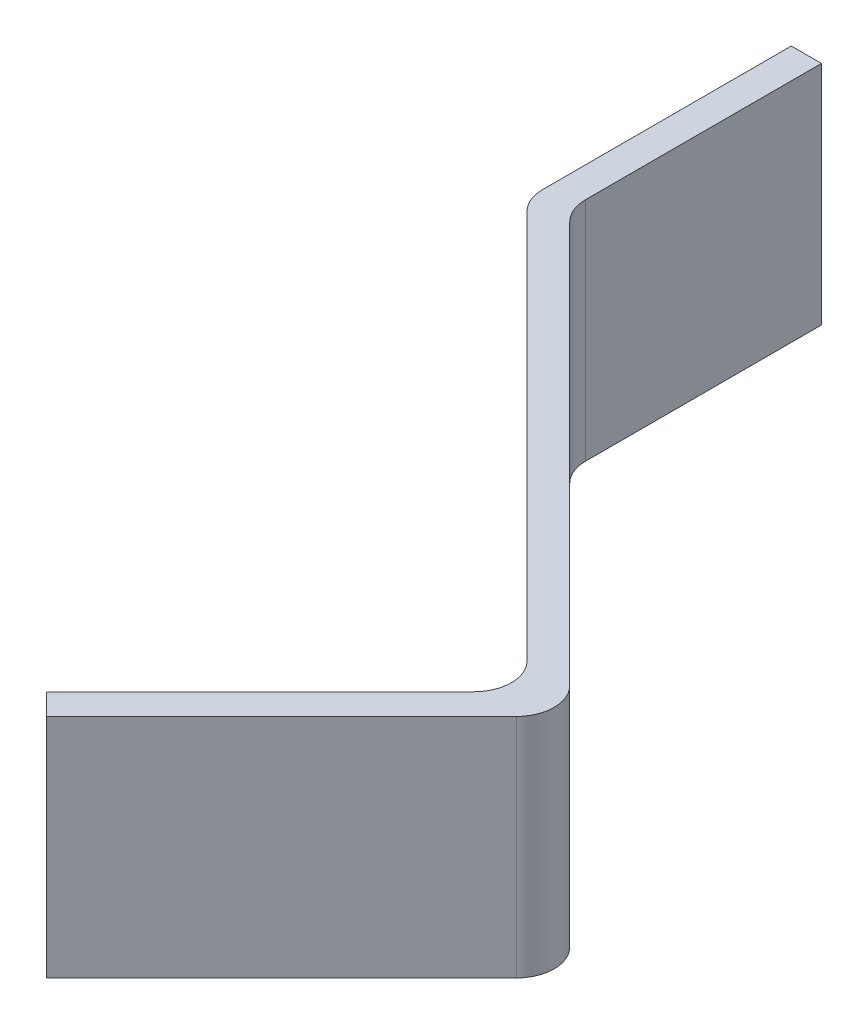
from build123d import *

# Parameters (mm, degrees)
BOSS_EXTRUDE1_DEPTH = 30


with BuildPart() as part:
    # Sketch1 → Boss-Extrude1 (new body)
    with BuildSketch(Plane(origin=(0, 7.5, 0), x_dir=(1, 0, 0), z_dir=(0, 1, 0))):
        with BuildLine():
            Line((248.792121733, 5.17665535), (195.566724989, 58.402052094))
            ThreePointArc((195.566724989, 58.402052094), (194.482861232, 60.024168838), (194.102258895, 61.937586))
            Line((194.102258895, 61.937586), (194.102258895, 93.209663939))
            Line((194.102258895, 93.209663939), (190.102258895, 93.209663939))
            Line((190.102258895, 93.209663939), (190.102258895, 60.280731751))
            ThreePointArc((190.102258895, 60.280731751), (190.482861232, 58.367314589), (191.566724989, 56.745197845))
            Line((191.566724989, 56.745197845), (243.135267484, 5.17665535))
            ThreePointArc((243.135267484, 5.17665535), (244.599733578, 1.641121444), (243.135267484, -1.894412462))
            Line((243.135267484, -1.894412462), (214.850996236, -30.178683709))
            Line((214.850996236, -30.178683709), (217.679423361, -33.007110834))
            Line((217.679423361, -33.007110834), (248.792121733, -1.894412462))
            ThreePointArc((248.792121733, -1.894412462), (250.256587827, 1.641121444), (248.792121733, 5.17665535))
        make_face()
    extrude(amount=-BOSS_EXTRUDE1_DEPTH)


solid = part.part
